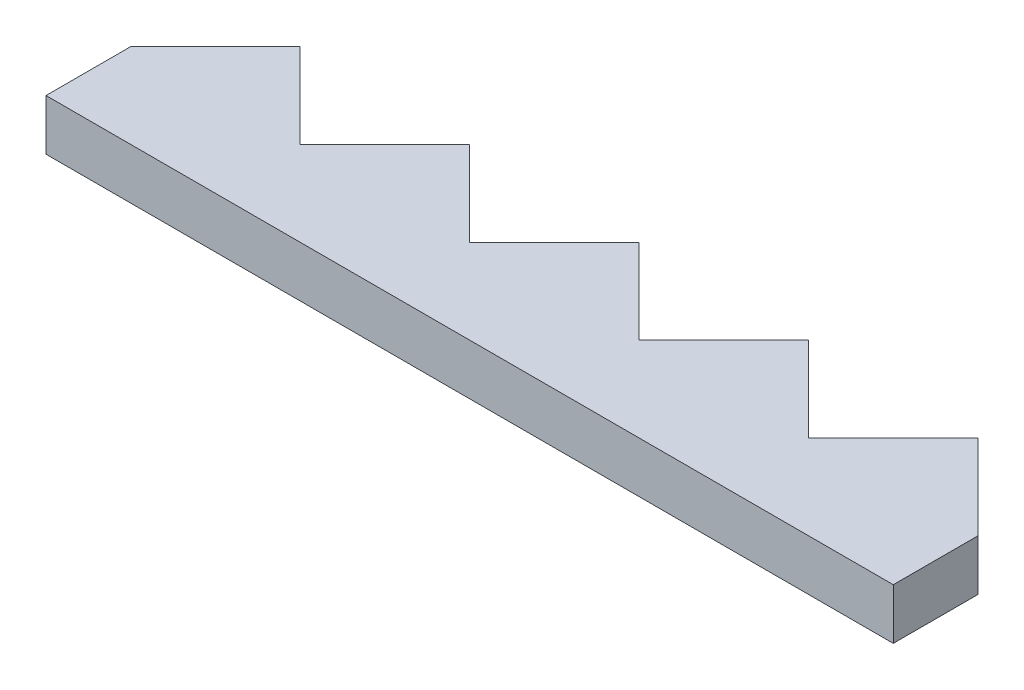
from build123d import *

# Parameters (mm, degrees)
BOSS_EXTRUDE1_DEPTH = 3


with BuildPart() as part:
    # Sketch1 → Boss-Extrude1 (new body)
    with BuildSketch(Plane(origin=(0, 0, 0), x_dir=(1, 0, 0), z_dir=(0, 1, 0))):
        Polygon((0, 5), (5, 10), (10, 5), (15, 10), (20, 5), (25, 10), (30, 5), (35, 10), (40, 5), (45, 10), (50, 5), (50, 0), (0, 0), align=None)
    extrude(amount=BOSS_EXTRUDE1_DEPTH)


solid = part.part
